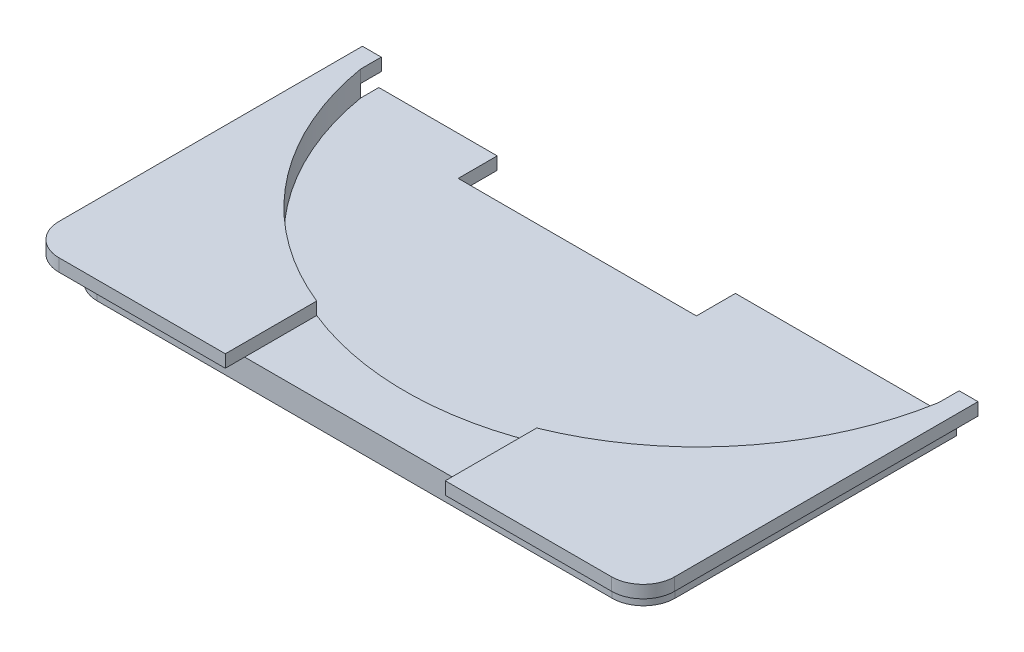
from build123d import *

# Parameters (mm, degrees)
BOSS_EXTRUDE2_DEPTH = 4
CUT_EXTRUDE3_DEPTH  = 4
SKETCH6_R           = 46.644893749
CUT_EXTRUDE4_DEPTH  = 2
SKETCH7_W           = 37.921763703
SKETCH7_H           = 21.966033547
CUT_EXTRUDE5_DEPTH  = 2
CUT_EXTRUDE7_DEPTH  = 10
BOSS_EXTRUDE3_DEPTH = 2


with BuildPart() as part:
    # Sketch4 → Boss-Extrude2 (new body)
    with BuildSketch(Plane(origin=(0, 0, 0), x_dir=(1, 0, 0), z_dir=(0, 1, 0))):
        with BuildLine():
            Line((-107.035735829, 49.14195745), (-15.035735829, 49.14195745))
            Line((-15.035735829, 49.14195745), (-15.035735829, -45.85804255))
            ThreePointArc((-15.035735829, -45.85804255), (-16.500201924, -49.393576456), (-20.035735829, -50.85804255))
            Line((-20.035735829, -50.85804255), (-102.035735829, -50.85804255))
            ThreePointArc((-102.035735829, -50.85804255), (-105.571269735, -49.393576456), (-107.035735829, -45.85804255))
            Line((-107.035735829, -45.85804255), (-107.035735829, 49.14195745))
        make_face()
    extrude(amount=BOSS_EXTRUDE2_DEPTH)

    # Sketch5 → Cut-Extrude3 (cut)
    with BuildSketch(Plane(origin=(0, 4, 0), x_dir=(1, 0, 0), z_dir=(0, 1, 0))):
        with BuildLine():
            Line((-122.184107688, 54.312207558), (-0.881081782, 54.312207558))
            Line((-0.881081782, 54.312207558), (-0.881081782, -1.763818638))
            Line((-0.881081782, -1.763818638), (-15.035735829, -1.763818638))
            ThreePointArc((-15.035735829, -1.763818638), (-61.035735829, 48.088703252), (-107.035735829, -1.763818638))
            Line((-107.035735829, -1.763818638), (-116.20594022, -1.763818638))
            Line((-116.20594022, -1.763818638), (-122.184107688, 54.312207558))
        make_face()
    extrude(amount=-CUT_EXTRUDE3_DEPTH, mode=Mode.SUBTRACT)

    # Sketch6 → Cut-Extrude4 (cut)
    with BuildSketch(Plane(origin=(0, 4, 0), x_dir=(1, 0, 0), z_dir=(0, 1, 0))):
        with Locations((-61.039241489, 3.84195745)):
            Circle(SKETCH6_R)
    extrude(amount=-CUT_EXTRUDE4_DEPTH, mode=Mode.SUBTRACT)

    # Sketch7 → Cut-Extrude5 (cut)
    with BuildSketch(Plane(origin=(0, 2, 0), x_dir=(1, 0, 0), z_dir=(0, 1, 0))):
        with Locations((-69.228954178, 3.760987583)):
            Rectangle(SKETCH7_W, SKETCH7_H)
    extrude(amount=-CUT_EXTRUDE5_DEPTH, mode=Mode.SUBTRACT)

    # Sketch8 → Cut-Extrude7 (cut)
    with BuildSketch(Plane(origin=(0, 2, 0), x_dir=(1, 0, 0), z_dir=(0, 1, 0))):
        Polygon((-107.035735829, 51.823370687), (-12.035735829, 51.823370687), (-15.035735829, -1.011363006), (-107.035735829, -1.011363006), align=None)
    extrude(amount=-CUT_EXTRUDE7_DEPTH, mode=Mode.SUBTRACT)

    # Sketch10 → Boss-Extrude3 (add)
    with BuildSketch(Plane(origin=(0, 4, 0), x_dir=(1, 0, 0), z_dir=(0, 1, 0))):
        with BuildLine():
            Line((-110.035735829, -0.626443871), (-107.035735829, -0.626443871))
            Line((-107.035735829, -0.626443871), (-107.035735829, -3.908437462))
            ThreePointArc((-107.035735829, -3.908437462), (-97.412251623, -25.359930275), (-78.547707812, -39.392284997))
            Line((-78.547707812, -39.392284997), (-78.547707812, -53.939312876))
            Line((-78.547707812, -53.939312876), (-105.035735829, -53.939312876))
            ThreePointArc((-105.035735829, -53.939312876), (-108.571269735, -52.474846782), (-110.035735829, -48.939312876))
            Line((-110.035735829, -48.939312876), (-110.035735829, -0.626443871))
        make_face()
        with BuildLine():
            Line((-12.035735829, -0.626443871), (-12.035735829, -48.939312876))
            ThreePointArc((-12.035735829, -48.939312876), (-13.500201924, -52.474846782), (-17.035735829, -53.939312876))
            Line((-17.035735829, -53.939312876), (-43.530775166, -53.939312876))
            Line((-43.530775166, -53.939312876), (-43.530775166, -39.392284997))
            ThreePointArc((-43.530775166, -39.392284997), (-24.652990845, -25.343430622), (-15.035735829, -3.86671169))
            Line((-15.035735829, -3.86671169), (-15.035735829, -0.626443871))
            Line((-15.035735829, -0.626443871), (-12.035735829, -0.626443871))
        make_face()
    extrude(amount=BOSS_EXTRUDE3_DEPTH)


solid = part.part
